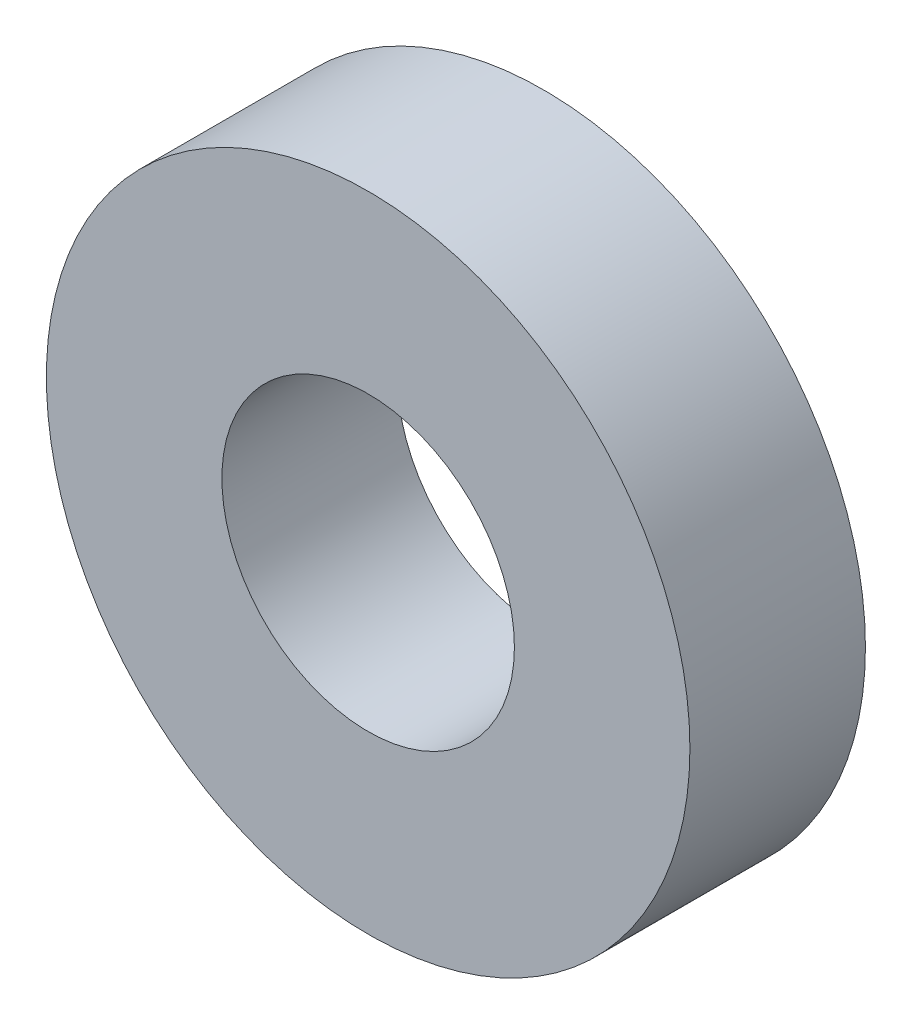
from build123d import *

# Parameters (mm, degrees)
ESQUISSE1_R        = 5.5
ESQUISSE1_R_2      = 2.5
BOSS_EXTRU_1_DEPTH = 3


with BuildPart() as part:
    # Esquisse1 → Boss.-Extru.1 (new body)
    with BuildSketch(Plane.XY):
        Circle(ESQUISSE1_R)
        Circle(ESQUISSE1_R_2, mode=Mode.SUBTRACT)
    extrude(amount=BOSS_EXTRU_1_DEPTH)


solid = part.part
